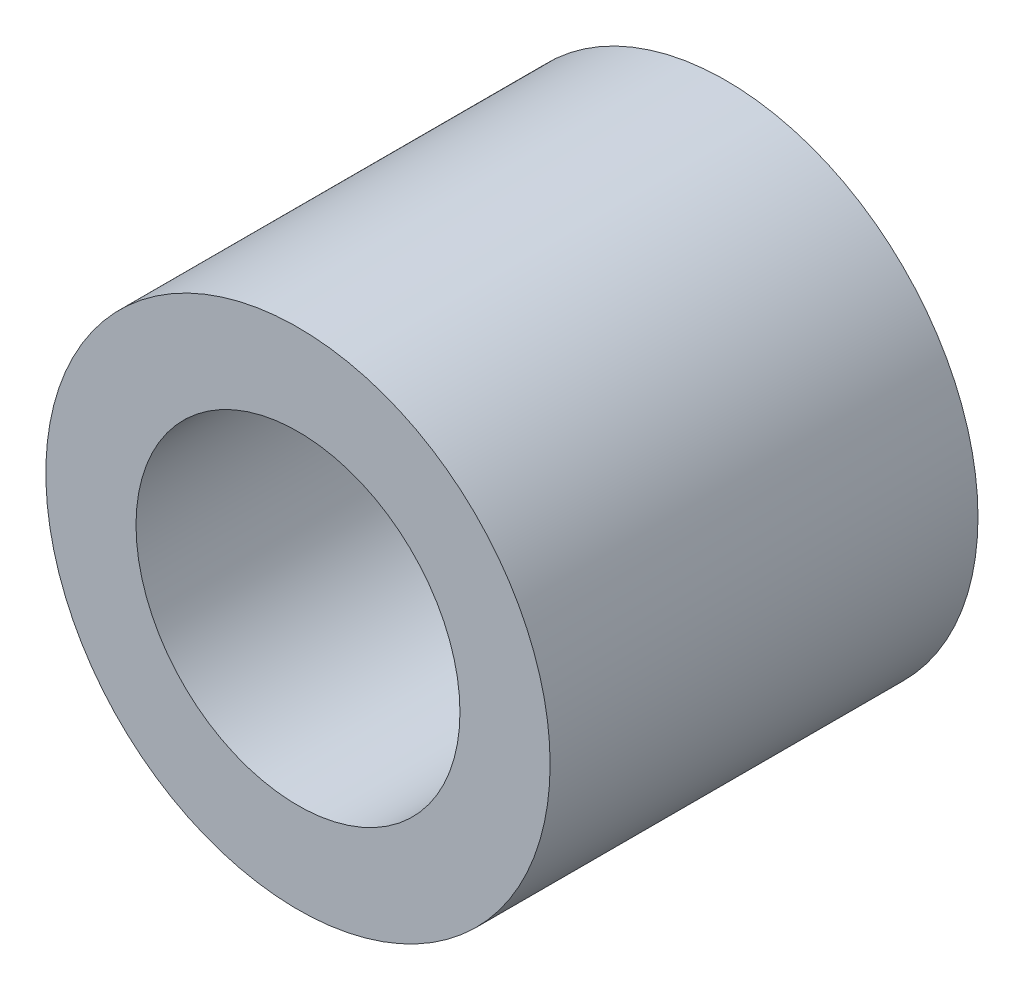
from build123d import *

# Parameters (mm, degrees)
SKETCH1_R            = 4.125
BOSS_EXTRUDE1_DEPTH  = 7
M5_CLEARANCE_HOLE1_D = 5.3


with BuildPart() as part:
    # Sketch1 → Boss-Extrude1 (new body)
    with BuildSketch(Plane.XY):
        Circle(SKETCH1_R)
    extrude(amount=BOSS_EXTRUDE1_DEPTH)

    # M5 Clearance Hole1 (through all)
    with Locations(Plane.XY.offset(7)):
        with Locations((0, 0)):
            Hole(M5_CLEARANCE_HOLE1_D / 2)


solid = part.part
